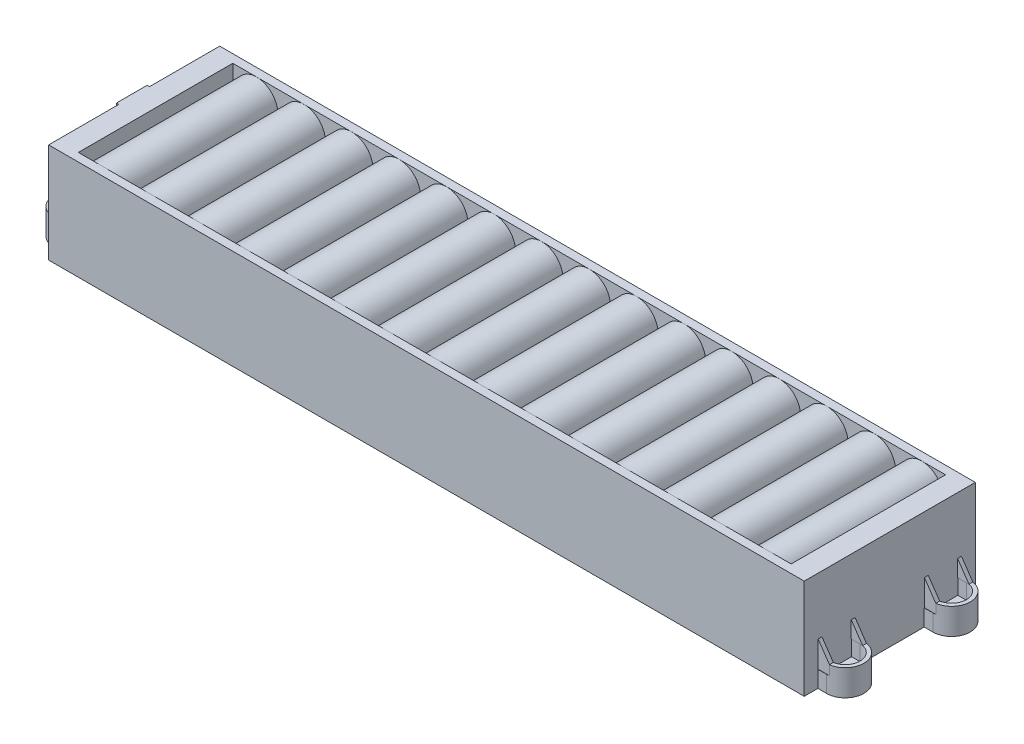
from build123d import *

# Parameters (mm, degrees)
SKETCH1_W                                = 318
SKETCH1_H                                = 72
BOSS_EXTRUDE1_DEPTH                      = 42
BOSS_EXTRUDE2_DEPTH                      = 11
BOSS_EXTRUDE2_2_DEPTH                    = 11
BOSS_EXTRUDE2_3_DEPTH                    = 11
BOSS_EXTRUDE2_4_DEPTH                    = 11
BOSS_EXTRUDE3_DEPTH                      = 4.5
MIRROR5_AT_THE_SECOND_PLANE_COPY_1_DEPTH = 4.5
CUT_EXTRUDE1_DEPTH                       = 32.5
LPATTERN1_COUNT                          = 15
LPATTERN1_PITCH                          = 20
MIRROR7_COPY_1_DEPTH                     = 32.5
MIRROR7_COPY_2_DEPTH                     = 32.5
MIRROR7_COPY_3_DEPTH                     = 32.5
MIRROR7_COPY_4_DEPTH                     = 32.5
MIRROR7_COPY_5_DEPTH                     = 32.5
MIRROR7_COPY_6_DEPTH                     = 32.5
MIRROR7_COPY_7_DEPTH                     = 32.5
MIRROR7_COPY_8_DEPTH                     = 32.5
MIRROR7_COPY_9_DEPTH                     = 32.5
MIRROR7_COPY_10_DEPTH                    = 32.5
MIRROR7_COPY_11_DEPTH                    = 32.5
MIRROR7_COPY_12_DEPTH                    = 32.5
MIRROR7_COPY_13_DEPTH                    = 32.5
MIRROR7_COPY_14_DEPTH                    = 32.5
BOSS_EXTRUDE4_DEPTH                      = 72
SKETCH6_W                                = 4.8
SKETCH6_H                                = 5.838152114
SKETCH6_H_2                              = 12.328016872
SKETCH6_H_3                              = 29.176304228
CUT_EXTRUDE2_DEPTH                       = 35
SKETCH7_W                                = 13
SKETCH7_H                                = 10
BOSS_EXTRUDE5_DEPTH                      = 1
SKETCH8_R                                = 4.75
BOSS_EXTRUDE6_DEPTH                      = 6.5


with BuildPart() as part:
    # Sketch1 → Boss-Extrude1 (new body)
    with BuildSketch(Plane(origin=(0, 0, 0), x_dir=(1, 0, 0), z_dir=(0, 1, 0))):
        Rectangle(SKETCH1_W, SKETCH1_H)
    extrude(amount=BOSS_EXTRUDE1_DEPTH)



with BuildPart() as body_2:
    # Sketch2 → Boss-Extrude2 (new body)
    with BuildSketch(Plane.XZ):
        with BuildLine():
            Line((162.625, 14.5), (159, 14.5))
            Line((159, 14.5), (159, 16.1))
            Line((159, 16.1), (162.625, 16.1))
            ThreePointArc((162.625, 16.1), (168.9, 22.375), (162.625, 28.65))
            Line((162.625, 28.65), (159, 28.65))
            Line((159, 28.65), (159, 30.25))
            Line((159, 30.25), (162.625, 30.25))
            ThreePointArc((162.625, 30.25), (170.5, 22.375), (162.625, 14.5))
        make_face()
    extrude(amount=-BOSS_EXTRUDE2_DEPTH)


with BuildPart() as body_3:
    # Sketch2 → Boss-Extrude2 2 (new body)
    with BuildSketch(Plane.XZ):
        with BuildLine():
            Line((162.625, -14.5), (159, -14.5))
            Line((159, -14.5), (159, -16.1))
            Line((159, -16.1), (162.625, -16.1))
            ThreePointArc((162.625, -16.1), (168.9, -22.375), (162.625, -28.65))
            Line((162.625, -28.65), (159, -28.65))
            Line((159, -28.65), (159, -30.25))
            Line((159, -30.25), (162.625, -30.25))
            ThreePointArc((162.625, -30.25), (170.5, -22.375), (162.625, -14.5))
        make_face()
    extrude(amount=-BOSS_EXTRUDE2_2_DEPTH)


with BuildPart() as body_4:
    # Sketch2 → Boss-Extrude2 3 (new body)
    with BuildSketch(Plane.XZ):
        with BuildLine():
            Line((-162.625, -14.5), (-159, -14.5))
            Line((-159, -14.5), (-159, -16.1))
            Line((-159, -16.1), (-162.625, -16.1))
            ThreePointArc((-162.625, -16.1), (-168.9, -22.375), (-162.625, -28.65))
            Line((-162.625, -28.65), (-159, -28.65))
            Line((-159, -28.65), (-159, -30.25))
            Line((-159, -30.25), (-162.625, -30.25))
            ThreePointArc((-162.625, -30.25), (-170.5, -22.375), (-162.625, -14.5))
        make_face()
    extrude(amount=-BOSS_EXTRUDE2_3_DEPTH)


with BuildPart() as body_5:
    # Sketch2 → Boss-Extrude2 4 (new body)
    with BuildSketch(Plane.XZ):
        with BuildLine():
            Line((-162.625, 14.5), (-159, 14.5))
            Line((-159, 14.5), (-159, 16.1))
            Line((-159, 16.1), (-162.625, 16.1))
            ThreePointArc((-162.625, 16.1), (-168.9, 22.375), (-162.625, 28.65))
            Line((-162.625, 28.65), (-159, 28.65))
            Line((-159, 28.65), (-159, 30.25))
            Line((-159, 30.25), (-162.625, 30.25))
            ThreePointArc((-162.625, 30.25), (-170.5, 22.375), (-162.625, 14.5))
        make_face()
    extrude(amount=-BOSS_EXTRUDE2_4_DEPTH)


with BuildPart() as part_1:
    add(part.part)

    add(body_2.part)  # Boss-Extrude3 merges body 2
    # Sketch3 → Boss-Extrude3 (add)
    with BuildSketch(Plane.XZ):
        with BuildLine():
            Line((159, 28.65), (159, 16.1))
            Line((159, 16.1), (162.625, 16.1))
            ThreePointArc((162.625, 16.1), (168.9, 22.375), (162.625, 28.65))
            Line((162.625, 28.65), (159, 28.65))
        make_face()
        with BuildLine():
            Line((161.825, 24.55), (165.075, 24.55))
            ThreePointArc((165.075, 24.55), (167.25, 22.375), (165.075, 20.2))
            Line((165.075, 20.2), (161.825, 20.2))
            ThreePointArc((161.825, 20.2), (159.65, 22.375), (161.825, 24.55))
        make_face(mode=Mode.SUBTRACT)
    boss_extrude3 = extrude(amount=-BOSS_EXTRUDE3_DEPTH)

    # Mirror5: Boss-Extrude3 across plane
    add(boss_extrude3.mirror(Plane(origin=(0, 0, 0), x_dir=(0, 0, 1), z_dir=(1, 0, 0))))

    # Mirror5 at the second plane: Boss-Extrude3 across plane
    add(boss_extrude3.mirror(Plane.XY))

    # Mirror5 at the second plane copy 1 sketc → Mirror5 at the second plane copy 1 (add)
    with BuildSketch(Plane(origin=(0, 0, 0), x_dir=(-1, 0, 0), z_dir=(0, -1, 0))):
        with BuildLine():
            Line((159, 28.65), (159, 16.1))
            Line((159, 16.1), (162.625, 16.1))
            ThreePointArc((162.625, 16.1), (168.9, 22.375), (162.625, 28.65))
            Line((162.625, 28.65), (159, 28.65))
        make_face()
        with BuildLine():
            Line((161.825, 24.55), (165.075, 24.55))
            ThreePointArc((165.075, 24.55), (167.25, 22.375), (165.075, 20.2))
            Line((165.075, 20.2), (161.825, 20.2))
            ThreePointArc((161.825, 20.2), (159.65, 22.375), (161.825, 24.55))
        make_face(mode=Mode.SUBTRACT)
    extrude(amount=-MIRROR5_AT_THE_SECOND_PLANE_COPY_1_DEPTH)

    # Sketch4 → Cut-Extrude1 (cut, symmetric)
    with BuildSketch(Plane.XY):
        with BuildLine():
            ThreePointArc((-149, 33), (-146.363961031, 39.363961031), (-140, 42))
            Line((-140, 42), (-150, 42))
            Line((-150, 42), (-150, 33))
            Line((-150, 33), (-149, 33))
        make_face()
        with BuildLine():
            ThreePointArc((-140, 42), (-133.636038969, 39.363961031), (-131, 33))
            Line((-131, 33), (-130, 33))
            Line((-130, 33), (-130, 42))
            Line((-130, 42), (-140, 42))
        make_face()
    cut_extrude1 = extrude(amount=CUT_EXTRUDE1_DEPTH, both=True, mode=Mode.SUBTRACT)

    # LPattern1: Cut-Extrude1 ×15
    with Locations(*[(i * LPATTERN1_PITCH, 0, 0) for i in range(1, LPATTERN1_COUNT)]):
        add(cut_extrude1, mode=Mode.SUBTRACT)

    # Mirror7: Cut-Extrude1 across plane
    add(cut_extrude1.mirror(Plane(origin=(0, 21, 0), x_dir=(0, 0, 1), z_dir=(0, -1, 0))), mode=Mode.SUBTRACT)

    # Mirror7 copy 1 sketch → Mirror7 copy 1 (cut, symmetric)
    with BuildSketch(Plane(origin=(20, 42, 0), x_dir=(1, 0, 0), z_dir=(0, 0, 1))):
        with BuildLine():
            ThreePointArc((-149, -33), (-146.363961031, -39.363961031), (-140, -42))
            Line((-140, -42), (-150, -42))
            Line((-150, -42), (-150, -33))
            Line((-150, -33), (-149, -33))
        make_face()
        with BuildLine():
            ThreePointArc((-140, -42), (-133.636038969, -39.363961031), (-131, -33))
            Line((-131, -33), (-130, -33))
            Line((-130, -33), (-130, -42))
            Line((-130, -42), (-140, -42))
        make_face()
    extrude(amount=MIRROR7_COPY_1_DEPTH, both=True, mode=Mode.SUBTRACT)

    # Mirror7 copy 2 sketch → Mirror7 copy 2 (cut, symmetric)
    with BuildSketch(Plane(origin=(40, 42, 0), x_dir=(1, 0, 0), z_dir=(0, 0, 1))):
        with BuildLine():
            ThreePointArc((-149, -33), (-146.363961031, -39.363961031), (-140, -42))
            Line((-140, -42), (-150, -42))
            Line((-150, -42), (-150, -33))
            Line((-150, -33), (-149, -33))
        make_face()
        with BuildLine():
            ThreePointArc((-140, -42), (-133.636038969, -39.363961031), (-131, -33))
            Line((-131, -33), (-130, -33))
            Line((-130, -33), (-130, -42))
            Line((-130, -42), (-140, -42))
        make_face()
    extrude(amount=MIRROR7_COPY_2_DEPTH, both=True, mode=Mode.SUBTRACT)

    # Mirror7 copy 3 sketch → Mirror7 copy 3 (cut, symmetric)
    with BuildSketch(Plane(origin=(60, 42, 0), x_dir=(1, 0, 0), z_dir=(0, 0, 1))):
        with BuildLine():
            ThreePointArc((-149, -33), (-146.363961031, -39.363961031), (-140, -42))
            Line((-140, -42), (-150, -42))
            Line((-150, -42), (-150, -33))
            Line((-150, -33), (-149, -33))
        make_face()
        with BuildLine():
            ThreePointArc((-140, -42), (-133.636038969, -39.363961031), (-131, -33))
            Line((-131, -33), (-130, -33))
            Line((-130, -33), (-130, -42))
            Line((-130, -42), (-140, -42))
        make_face()
    extrude(amount=MIRROR7_COPY_3_DEPTH, both=True, mode=Mode.SUBTRACT)

    # Mirror7 copy 4 sketch → Mirror7 copy 4 (cut, symmetric)
    with BuildSketch(Plane(origin=(80, 42, 0), x_dir=(1, 0, 0), z_dir=(0, 0, 1))):
        with BuildLine():
            ThreePointArc((-149, -33), (-146.363961031, -39.363961031), (-140, -42))
            Line((-140, -42), (-150, -42))
            Line((-150, -42), (-150, -33))
            Line((-150, -33), (-149, -33))
        make_face()
        with BuildLine():
            ThreePointArc((-140, -42), (-133.636038969, -39.363961031), (-131, -33))
            Line((-131, -33), (-130, -33))
            Line((-130, -33), (-130, -42))
            Line((-130, -42), (-140, -42))
        make_face()
    extrude(amount=MIRROR7_COPY_4_DEPTH, both=True, mode=Mode.SUBTRACT)

    # Mirror7 copy 5 sketch → Mirror7 copy 5 (cut, symmetric)
    with BuildSketch(Plane(origin=(100, 42, 0), x_dir=(1, 0, 0), z_dir=(0, 0, 1))):
        with BuildLine():
            ThreePointArc((-149, -33), (-146.363961031, -39.363961031), (-140, -42))
            Line((-140, -42), (-150, -42))
            Line((-150, -42), (-150, -33))
            Line((-150, -33), (-149, -33))
        make_face()
        with BuildLine():
            ThreePointArc((-140, -42), (-133.636038969, -39.363961031), (-131, -33))
            Line((-131, -33), (-130, -33))
            Line((-130, -33), (-130, -42))
            Line((-130, -42), (-140, -42))
        make_face()
    extrude(amount=MIRROR7_COPY_5_DEPTH, both=True, mode=Mode.SUBTRACT)

    # Mirror7 copy 6 sketch → Mirror7 copy 6 (cut, symmetric)
    with BuildSketch(Plane(origin=(120, 42, 0), x_dir=(1, 0, 0), z_dir=(0, 0, 1))):
        with BuildLine():
            ThreePointArc((-149, -33), (-146.363961031, -39.363961031), (-140, -42))
            Line((-140, -42), (-150, -42))
            Line((-150, -42), (-150, -33))
            Line((-150, -33), (-149, -33))
        make_face()
        with BuildLine():
            ThreePointArc((-140, -42), (-133.636038969, -39.363961031), (-131, -33))
            Line((-131, -33), (-130, -33))
            Line((-130, -33), (-130, -42))
            Line((-130, -42), (-140, -42))
        make_face()
    extrude(amount=MIRROR7_COPY_6_DEPTH, both=True, mode=Mode.SUBTRACT)

    # Mirror7 copy 7 sketch → Mirror7 copy 7 (cut, symmetric)
    with BuildSketch(Plane(origin=(140, 42, 0), x_dir=(1, 0, 0), z_dir=(0, 0, 1))):
        with BuildLine():
            ThreePointArc((-149, -33), (-146.363961031, -39.363961031), (-140, -42))
            Line((-140, -42), (-150, -42))
            Line((-150, -42), (-150, -33))
            Line((-150, -33), (-149, -33))
        make_face()
        with BuildLine():
            ThreePointArc((-140, -42), (-133.636038969, -39.363961031), (-131, -33))
            Line((-131, -33), (-130, -33))
            Line((-130, -33), (-130, -42))
            Line((-130, -42), (-140, -42))
        make_face()
    extrude(amount=MIRROR7_COPY_7_DEPTH, both=True, mode=Mode.SUBTRACT)

    # Mirror7 copy 8 sketch → Mirror7 copy 8 (cut, symmetric)
    with BuildSketch(Plane(origin=(160, 42, 0), x_dir=(1, 0, 0), z_dir=(0, 0, 1))):
        with BuildLine():
            ThreePointArc((-149, -33), (-146.363961031, -39.363961031), (-140, -42))
            Line((-140, -42), (-150, -42))
            Line((-150, -42), (-150, -33))
            Line((-150, -33), (-149, -33))
        make_face()
        with BuildLine():
            ThreePointArc((-140, -42), (-133.636038969, -39.363961031), (-131, -33))
            Line((-131, -33), (-130, -33))
            Line((-130, -33), (-130, -42))
            Line((-130, -42), (-140, -42))
        make_face()
    extrude(amount=MIRROR7_COPY_8_DEPTH, both=True, mode=Mode.SUBTRACT)

    # Mirror7 copy 9 sketch → Mirror7 copy 9 (cut, symmetric)
    with BuildSketch(Plane(origin=(180, 42, 0), x_dir=(1, 0, 0), z_dir=(0, 0, 1))):
        with BuildLine():
            ThreePointArc((-149, -33), (-146.363961031, -39.363961031), (-140, -42))
            Line((-140, -42), (-150, -42))
            Line((-150, -42), (-150, -33))
            Line((-150, -33), (-149, -33))
        make_face()
        with BuildLine():
            ThreePointArc((-140, -42), (-133.636038969, -39.363961031), (-131, -33))
            Line((-131, -33), (-130, -33))
            Line((-130, -33), (-130, -42))
            Line((-130, -42), (-140, -42))
        make_face()
    extrude(amount=MIRROR7_COPY_9_DEPTH, both=True, mode=Mode.SUBTRACT)

    # Mirror7 copy 10 sketch → Mirror7 copy 10 (cut, symmetric)
    with BuildSketch(Plane(origin=(200, 42, 0), x_dir=(1, 0, 0), z_dir=(0, 0, 1))):
        with BuildLine():
            ThreePointArc((-149, -33), (-146.363961031, -39.363961031), (-140, -42))
            Line((-140, -42), (-150, -42))
            Line((-150, -42), (-150, -33))
            Line((-150, -33), (-149, -33))
        make_face()
        with BuildLine():
            ThreePointArc((-140, -42), (-133.636038969, -39.363961031), (-131, -33))
            Line((-131, -33), (-130, -33))
            Line((-130, -33), (-130, -42))
            Line((-130, -42), (-140, -42))
        make_face()
    extrude(amount=MIRROR7_COPY_10_DEPTH, both=True, mode=Mode.SUBTRACT)

    # Mirror7 copy 11 sketch → Mirror7 copy 11 (cut, symmetric)
    with BuildSketch(Plane(origin=(220, 42, 0), x_dir=(1, 0, 0), z_dir=(0, 0, 1))):
        with BuildLine():
            ThreePointArc((-149, -33), (-146.363961031, -39.363961031), (-140, -42))
            Line((-140, -42), (-150, -42))
            Line((-150, -42), (-150, -33))
            Line((-150, -33), (-149, -33))
        make_face()
        with BuildLine():
            ThreePointArc((-140, -42), (-133.636038969, -39.363961031), (-131, -33))
            Line((-131, -33), (-130, -33))
            Line((-130, -33), (-130, -42))
            Line((-130, -42), (-140, -42))
        make_face()
    extrude(amount=MIRROR7_COPY_11_DEPTH, both=True, mode=Mode.SUBTRACT)

    # Mirror7 copy 12 sketch → Mirror7 copy 12 (cut, symmetric)
    with BuildSketch(Plane(origin=(240, 42, 0), x_dir=(1, 0, 0), z_dir=(0, 0, 1))):
        with BuildLine():
            ThreePointArc((-149, -33), (-146.363961031, -39.363961031), (-140, -42))
            Line((-140, -42), (-150, -42))
            Line((-150, -42), (-150, -33))
            Line((-150, -33), (-149, -33))
        make_face()
        with BuildLine():
            ThreePointArc((-140, -42), (-133.636038969, -39.363961031), (-131, -33))
            Line((-131, -33), (-130, -33))
            Line((-130, -33), (-130, -42))
            Line((-130, -42), (-140, -42))
        make_face()
    extrude(amount=MIRROR7_COPY_12_DEPTH, both=True, mode=Mode.SUBTRACT)

    # Mirror7 copy 13 sketch → Mirror7 copy 13 (cut, symmetric)
    with BuildSketch(Plane(origin=(260, 42, 0), x_dir=(1, 0, 0), z_dir=(0, 0, 1))):
        with BuildLine():
            ThreePointArc((-149, -33), (-146.363961031, -39.363961031), (-140, -42))
            Line((-140, -42), (-150, -42))
            Line((-150, -42), (-150, -33))
            Line((-150, -33), (-149, -33))
        make_face()
        with BuildLine():
            ThreePointArc((-140, -42), (-133.636038969, -39.363961031), (-131, -33))
            Line((-131, -33), (-130, -33))
            Line((-130, -33), (-130, -42))
            Line((-130, -42), (-140, -42))
        make_face()
    extrude(amount=MIRROR7_COPY_13_DEPTH, both=True, mode=Mode.SUBTRACT)

    # Mirror7 copy 14 sketch → Mirror7 copy 14 (cut, symmetric)
    with BuildSketch(Plane(origin=(280, 42, 0), x_dir=(1, 0, 0), z_dir=(0, 0, 1))):
        with BuildLine():
            ThreePointArc((-149, -33), (-146.363961031, -39.363961031), (-140, -42))
            Line((-140, -42), (-150, -42))
            Line((-150, -42), (-150, -33))
            Line((-150, -33), (-149, -33))
        make_face()
        with BuildLine():
            ThreePointArc((-140, -42), (-133.636038969, -39.363961031), (-131, -33))
            Line((-131, -33), (-130, -33))
            Line((-130, -33), (-130, -42))
            Line((-130, -42), (-140, -42))
        make_face()
    extrude(amount=MIRROR7_COPY_14_DEPTH, both=True, mode=Mode.SUBTRACT)


    add(body_3.part)  # Boss-Extrude4 merges body 3
    # Sketch5 → Boss-Extrude4 (add, through all)
    with BuildSketch(Plane.XY.offset(36)):
        Polygon((159, 11), (163.8, 11), (159, 18), align=None)
    extrude(amount=-BOSS_EXTRUDE4_DEPTH)

    # Sketch6 → Cut-Extrude2 (cut)
    with BuildSketch(Plane(origin=(0, 42, 0), x_dir=(1, 0, 0), z_dir=(0, 1, 0))):
        with Locations((161.4, -33.080923943)):
            Rectangle(SKETCH6_W, SKETCH6_H)
        with Locations((161.4, -22.375)):
            Rectangle(SKETCH6_W, SKETCH6_H_2)
        with Locations((161.4, 0)):
            Rectangle(SKETCH6_W, SKETCH6_H_3)
        with Locations((161.4, 22.375)):
            Rectangle(SKETCH6_W, SKETCH6_H_2)
        with Locations((161.4, 33.080923943)):
            Rectangle(SKETCH6_W, SKETCH6_H)
    extrude(amount=-CUT_EXTRUDE2_DEPTH, mode=Mode.SUBTRACT)

    # Sketch7 → Boss-Extrude5 (add)
    with BuildSketch(Plane.ZY.offset(159)):
        with Locations((0, 37)):
            Rectangle(SKETCH7_W, SKETCH7_H)
    extrude(amount=BOSS_EXTRUDE5_DEPTH)


    add(body_5.part)  # Boss-Extrude6 merges body 5
    # Sketch8 → Boss-Extrude6 (add)
    with BuildSketch(Plane(origin=(0, 4.5, 0), x_dir=(1, 0, 0), z_dir=(0, 1, 0))):
        with BuildLine():
            Line((-162.625, -28.65), (-159, -28.65))
            Line((-159, -28.65), (-159, -16.1))
            Line((-159, -16.1), (-162.625, -16.1))
            ThreePointArc((-162.625, -16.1), (-168.9, -22.375), (-162.625, -28.65))
        make_face()
        with Locations((-164, -22.375)):
            Circle(SKETCH8_R, mode=Mode.SUBTRACT)
    boss_extrude6 = extrude(amount=BOSS_EXTRUDE6_DEPTH)

    # Mirror8: Boss-Extrude6 across plane
    add(boss_extrude6.mirror(Plane.XY))


solid = Compound([body_4.part, part_1.part])
